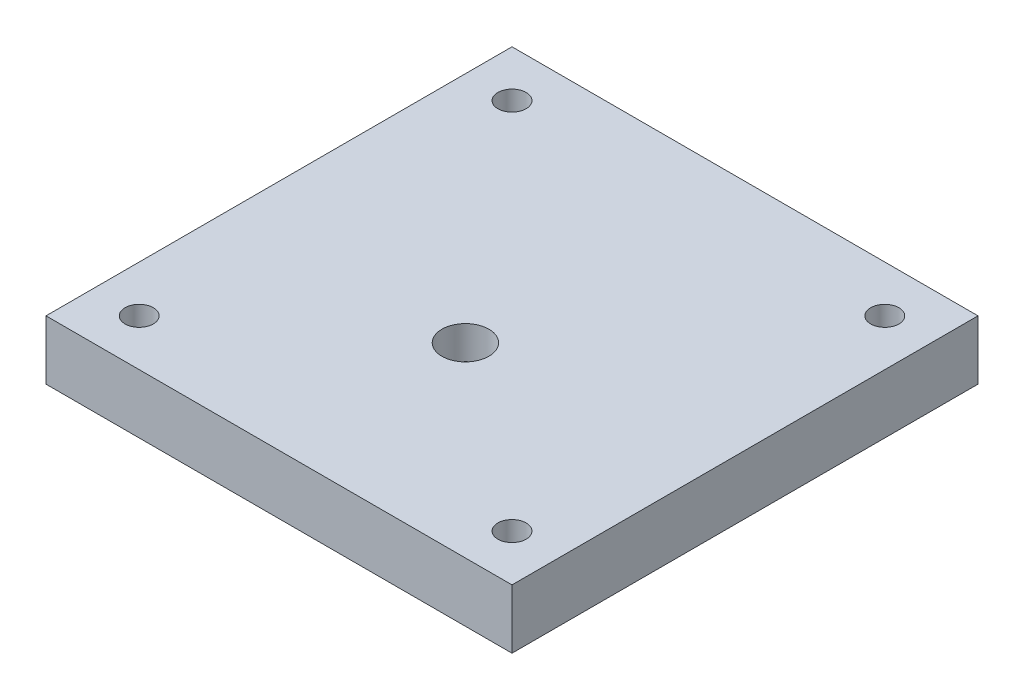
from build123d import *

# Parameters (mm, degrees)
SKETCH1_W                                           = 100
SKETCH1_H                                           = 100
BOSS_EXTRUDE1_DEPTH                                 = 12.7
M5_CLEARANCE_HOLE1_D                                = 6.06
CSK_FOR_3_8_FLAT_HEAD_SOCKET_CAP_SCREW1_D           = 10.0838
CSK_FOR_3_8_FLAT_HEAD_SOCKET_CAP_SCREW1_CSINK_D     = 19.8374
CSK_FOR_3_8_FLAT_HEAD_SOCKET_CAP_SCREW1_CSINK_ANGLE = 82


with BuildPart() as part:
    # Sketch1 → Boss-Extrude1 (new body)
    with BuildSketch(Plane(origin=(0, 0, 0), x_dir=(1, 0, 0), z_dir=(0, 1, 0))):
        with Locations((0, 10)):
            Rectangle(SKETCH1_W, SKETCH1_H)
    extrude(amount=BOSS_EXTRUDE1_DEPTH)

    # M5 Clearance Hole1 (through all)
    with Locations(Plane(origin=(0, 12.7, 0), x_dir=(1, 0, 0), z_dir=(0, 1, 0))):
        with Locations((-40, 50), (40, 50), (40, -30), (-40, -30)):
            Hole(M5_CLEARANCE_HOLE1_D / 2)

    # CSK for 3_8 Flat Head Socket Cap Screw1 (through all)
    with Locations(Plane(origin=(0, 0, 0), x_dir=(-1, 0, 0), z_dir=(0, -1, 0))):
        with Locations((0, 0)):
            CounterSinkHole(CSK_FOR_3_8_FLAT_HEAD_SOCKET_CAP_SCREW1_D / 2, CSK_FOR_3_8_FLAT_HEAD_SOCKET_CAP_SCREW1_CSINK_D / 2, counter_sink_angle=CSK_FOR_3_8_FLAT_HEAD_SOCKET_CAP_SCREW1_CSINK_ANGLE)


solid = part.part
